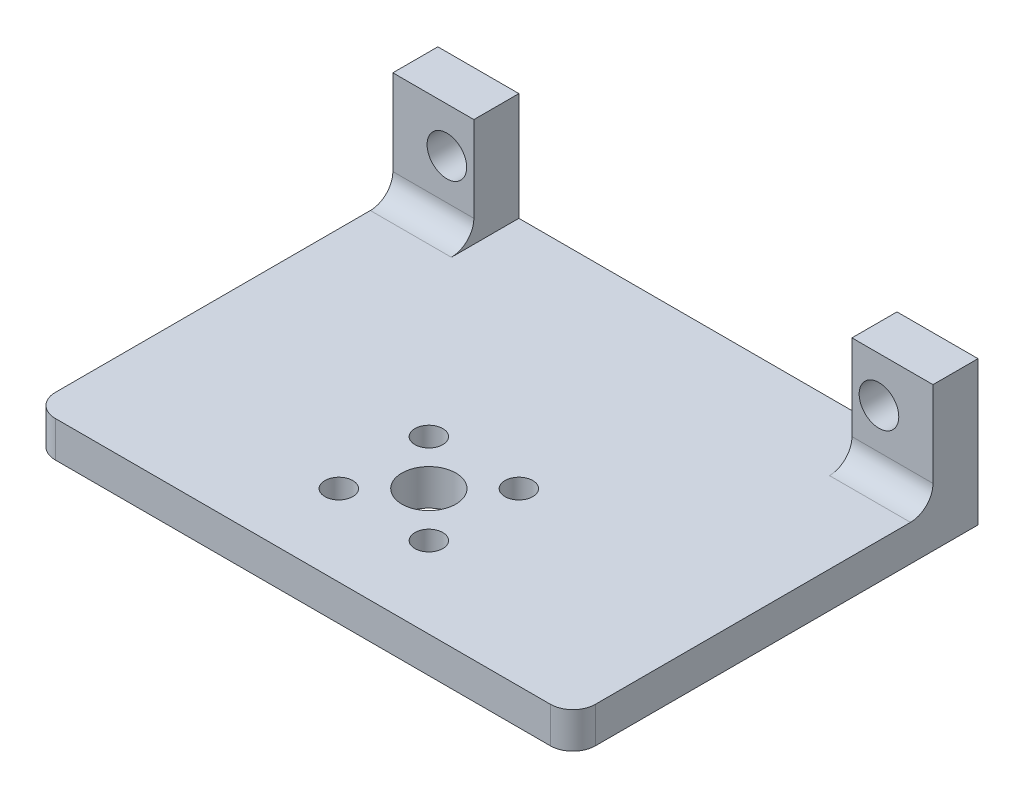
from build123d import *

# Parameters (mm, degrees)
SKETCH1_W           = 60
SKETCH1_H           = 4
BOSS_EXTRUDE1_DEPTH = 45
SKETCH1_3_W         = 9
SKETCH1_3_H         = 24
SKETCH1_3_R         = 2.2
BOSS_EXTRUDE2_DEPTH = 5
SKETCH2_R           = 3
SKETCH2_R_2         = 1.55
CUT_EXTRUDE1_DEPTH  = 124.088359511
BOSS_EXTRUDE3_DEPTH = 45
FILLET1_R           = 2.5
FILLET3_R           = 2.5
SKETCH3_R           = 4
BOSS_EXTRUDE4_DEPTH = 12
SKETCH4_R           = 6
BOSS_EXTRUDE5_DEPTH = 5
FILLET4_R           = 1
SKETCH5_W           = 46.619734532
SKETCH5_H           = 29.432499903
CUT_EXTRUDE3_DEPTH  = 89.875621116


with BuildPart() as part:
    # Sketch1 → Boss-Extrude1 (new body)
    with BuildSketch(Plane.XY):
        with Locations((-82.025641026, 5.685176195)):
            Rectangle(SKETCH1_W, SKETCH1_H)
    extrude(amount=BOSS_EXTRUDE1_DEPTH)

    # Sketch1_3 → Boss-Extrude2 (add)
    # profile 1 of 2: a face of its own
    with BuildSketch(Plane.XY):
        with Locations((-107.525641026, 19.685176195)):
            Rectangle(SKETCH1_3_W, SKETCH1_3_H)
        with Locations((-106.025641026, 14.685176195)):
            Circle(SKETCH1_3_R, mode=Mode.SUBTRACT)
        with Locations((-106.025641026, 24.685176195)):
            Circle(SKETCH1_3_R, mode=Mode.SUBTRACT)
    # profile 2 of 2: a face of its own
    with BuildSketch(Plane.XY):
        with Locations((-56.525641026, 19.685176195)):
            Rectangle(SKETCH1_3_W, SKETCH1_3_H)
        with Locations((-58.025641026, 14.685176195)):
            Circle(SKETCH1_3_R, mode=Mode.SUBTRACT)
        with Locations((-58.025641026, 24.685176195)):
            Circle(SKETCH1_3_R, mode=Mode.SUBTRACT)
    extrude(amount=BOSS_EXTRUDE2_DEPTH)

    # Sketch2 → Cut-Extrude1 (cut, through all)
    with BuildSketch(Plane(origin=(0, 7.685176195, 0), x_dir=(1, 0, 0), z_dir=(0, 1, 0))):
        with Locations((-82.025641026, -31)):
            Circle(SKETCH2_R)
        with Locations((-77.025641026, -26)):
            Circle(SKETCH2_R_2)
        with Locations((-87.025641026, -26)):
            Circle(SKETCH2_R_2)
        with Locations((-77.025641026, -36)):
            Circle(SKETCH2_R_2)
        with Locations((-87.025641026, -36)):
            Circle(SKETCH2_R_2)
    extrude(amount=-CUT_EXTRUDE1_DEPTH, mode=Mode.SUBTRACT)

    # Sketch1_4 → Boss-Extrude3 (add)
    with BuildSketch(Plane.XY):
        Polygon((-112.025641026, 35.685176195), (-112.025641026, 31.685176195), (-103.025641026, 31.685176195), (-61.025641026, 31.685176195), (-52.025641026, 31.685176195), (-52.025641026, 35.685176195), align=None)
    extrude(amount=BOSS_EXTRUDE3_DEPTH)

    # Fillet1
    fillet1_edges = [part.edges().sort_by_distance(p)[0] for p in [
        (-52.025641026, 5.685176195, 45),
        (-112.025641026, 5.685176195, 45),
        (-52.025641026, 33.685176195, 45),
        (-112.025641026, 33.685176195, 45),
    ]]
    fillet(fillet1_edges, radius=FILLET1_R)

    # Fillet3
    fillet3_edges = [part.edges().sort_by_distance(p)[0] for p in [
        (-107.525641026, 7.685176195, 5),
        (-56.525641026, 7.685176195, 5),
        (-56.525641026, 31.685176195, 5),
        (-107.525641026, 31.685176195, 5),
    ]]
    fillet(fillet3_edges, radius=FILLET3_R)

    # Sketch3 → Boss-Extrude4 (add)
    with BuildSketch(Plane(origin=(0, 35.685176195, 0), x_dir=(1, 0, 0), z_dir=(0, 1, 0))):
        with Locations((-82.025641026, -31)):
            Circle(SKETCH3_R)
    extrude(amount=BOSS_EXTRUDE4_DEPTH)

    # Sketch4 → Boss-Extrude5 (add)
    with BuildSketch(Plane(origin=(0, 35.685176195, 0), x_dir=(1, 0, 0), z_dir=(0, 1, 0))):
        with Locations((-82.025641026, -31)):
            Circle(SKETCH4_R)
    extrude(amount=BOSS_EXTRUDE5_DEPTH)

    # Fillet4
    fillet4_edges = [part.edges().sort_by_distance(p)[0] for p in [
        (-86.025641026, 40.685176195, 31),
    ]]
    fillet(fillet4_edges, radius=FILLET4_R)

    # Sketch5 → Cut-Extrude3 (cut, through all)
    with BuildSketch(Plane.ZY.offset(112.025641026)):
        with Locations((23.309867266, 34.401426147)):
            Rectangle(SKETCH5_W, SKETCH5_H)
    extrude(amount=-CUT_EXTRUDE3_DEPTH, mode=Mode.SUBTRACT)


solid = part.part
